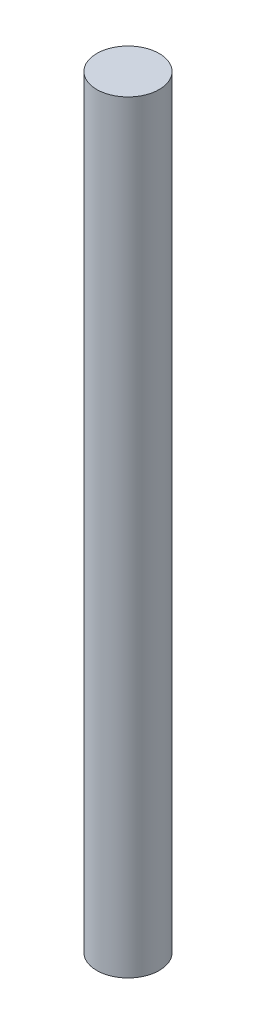
from build123d import *

# Parameters (mm, degrees)
SKETCH1_R           = 2.25
BOSS_EXTRUDE1_DEPTH = 55


with BuildPart() as part:
    # Sketch1 → Boss-Extrude1 (new body)
    with BuildSketch(Plane(origin=(0, 0, 0), x_dir=(1, 0, 0), z_dir=(0, 1, 0))):
        Circle(SKETCH1_R)
    extrude(amount=BOSS_EXTRUDE1_DEPTH)


solid = part.part
